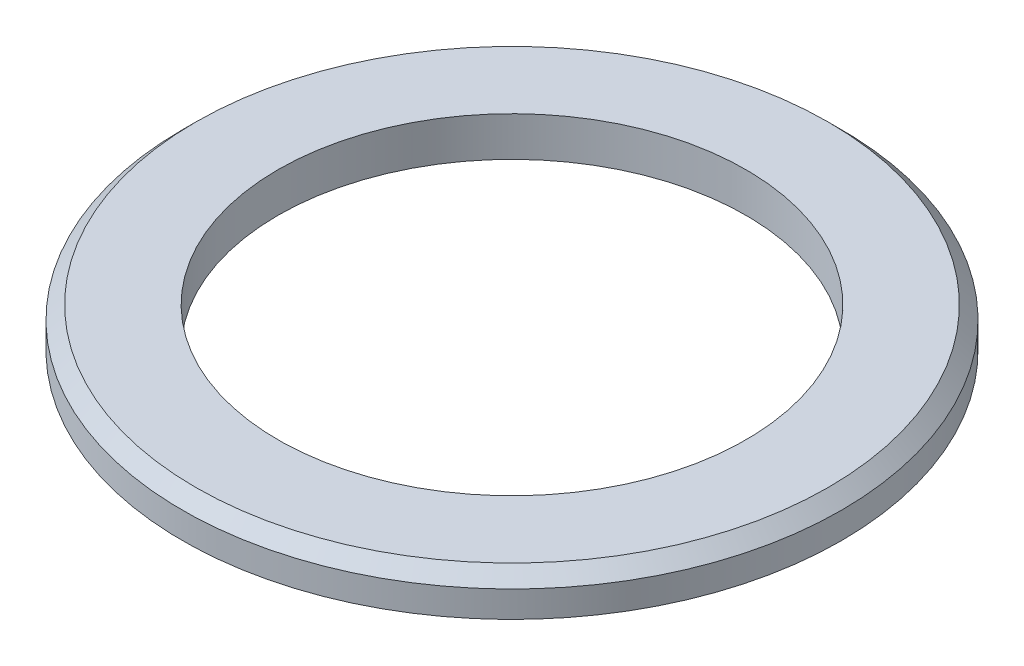
from build123d import *

# Parameters (mm, degrees)
SKETCH1_W          = 25
SKETCH1_H          = 3
SKETCH2_R          = 17.75
CUT_EXTRUDE1_DEPTH = 3
CHAMFER1_SIZE      = 1


with BuildPart() as part:
    # Sketch1 → Revolve1 (revolve)
    with BuildSketch(Plane.XY):
        with Locations((12.5, 1.5)):
            Rectangle(SKETCH1_W, SKETCH1_H)
    revolve(axis=Axis((25, 3, 0), (0, -1, 0)))

    # Sketch2 → Cut-Extrude1 (cut)
    with BuildSketch(Plane(origin=(0, 3, 0), x_dir=(1, 0, 0), z_dir=(0, 1, 0))):
        with Locations((25, 0)):
            Circle(SKETCH2_R)
    extrude(amount=-CUT_EXTRUDE1_DEPTH, mode=Mode.SUBTRACT)

    # Chamfer1
    chamfer1_edges = [part.edges().sort_by_distance(p)[0] for p in [
        (50, 3, 0),
    ]]
    chamfer(chamfer1_edges, length=CHAMFER1_SIZE)


solid = part.part
